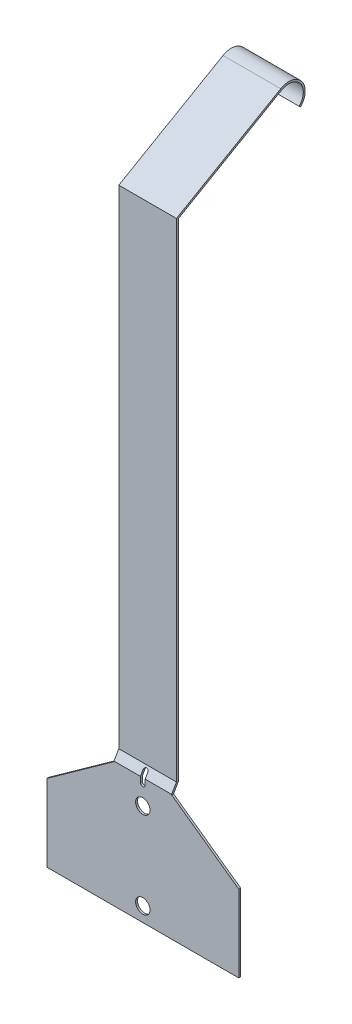
from build123d import *

# Parameters (mm, degrees)
EXTRUDE_THIN1_DEPTH         = 38.1
BOSS_EXTRUDE1_DEPTH         = 2.54
F_3_4_0_75_DIAMETER_HOLE1_D = 19.05
CUT_EXTRUDE1_DEPTH          = 177.53


with BuildPart() as part:
    # Sketch1 → Extrude-Thin1 (new body, symmetric)
    with BuildSketch(Plane(origin=(0, 0, 0), x_dir=(0, 0, -1), z_dir=(1, 0, 0))):
        with BuildLine():
            Line((0, 0), (0, 165.1))
            Line((0, 165.1), (6.35, 176.098522628))
            Line((6.35, 176.098522628), (6.35, 820.325038441))
            Line((6.35, 820.325038441), (142.875, 899.147783942))
            ThreePointArc((142.875, 899.147783942), (167.513381133, 894.246905223), (165.870384182, 869.179615818))
            Line((165.870384182, 869.179615818), (167.666435406, 867.383564594))
            ThreePointArc((167.666435406, 867.383564594), (169.528498617, 895.793159252), (141.605, 901.347488468))
            Line((141.605, 901.347488468), (3.81, 821.791508125))
            Line((3.81, 821.791508125), (3.81, 176.779113577))
            Line((3.81, 176.779113577), (-2.54, 165.780590949))
            Line((-2.54, 165.780590949), (-2.54, 0))
            Line((-2.54, 0), (0, 0))
        make_face()
    extrude(amount=EXTRUDE_THIN1_DEPTH, both=True)

    # Sketch5 → Boss-Extrude1 (add)
    with BuildSketch(Plane(origin=(0, 0, 0), x_dir=(-1, 0, 0), z_dir=(0, 0, -1))):
        Polygon((126.873, 0), (-126.873, 0), (-126.873, 101.6), (-38.1, 165.1), (38.1, 165.1), (126.873, 101.6), align=None)
    extrude(amount=-BOSS_EXTRUDE1_DEPTH)

    # 3/4 (0.75) Diameter Hole1 (through all)
    with Locations(Plane(origin=(0, 0, 0), x_dir=(-1, 0, 0), z_dir=(0, 0, -1))):
        with Locations((0, 19.05), (0, 133.35)):
            Hole(F_3_4_0_75_DIAMETER_HOLE1_D / 2)

    # Sketch4 → Cut-Extrude1 (cut, through all)
    with BuildSketch(Plane.XY.offset(2.54)):
        with BuildLine():
            Line((-3.175, 158.75), (-3.175, 171.45))
            ThreePointArc((-3.175, 171.45), (0, 174.625), (3.175, 171.45))
            Line((3.175, 171.45), (3.175, 158.75))
            ThreePointArc((3.175, 158.75), (0, 155.575), (-3.175, 158.75))
        make_face()
    extrude(amount=-CUT_EXTRUDE1_DEPTH, mode=Mode.SUBTRACT)


solid = part.part
